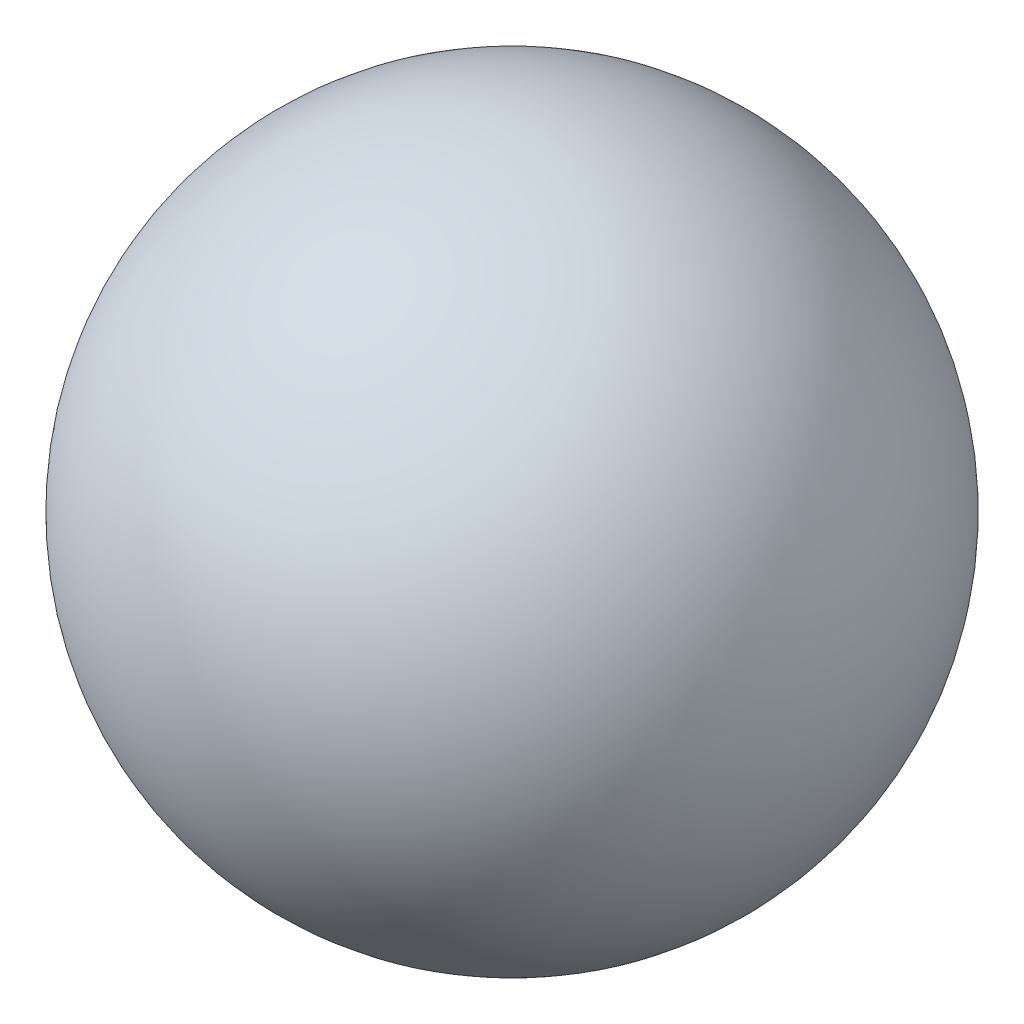
from build123d import *


with BuildPart() as part:
    # Sketch1 → Revolve1 (revolve)
    with BuildSketch(Plane.XY):
        with BuildLine():
            Line((0, 4), (0, -4))
            ThreePointArc((0, -4), (4, 0), (0, 4))
        make_face()
    revolve(axis=Axis((0, 9.478133447, 0), (0, -1, 0)))


solid = part.part
